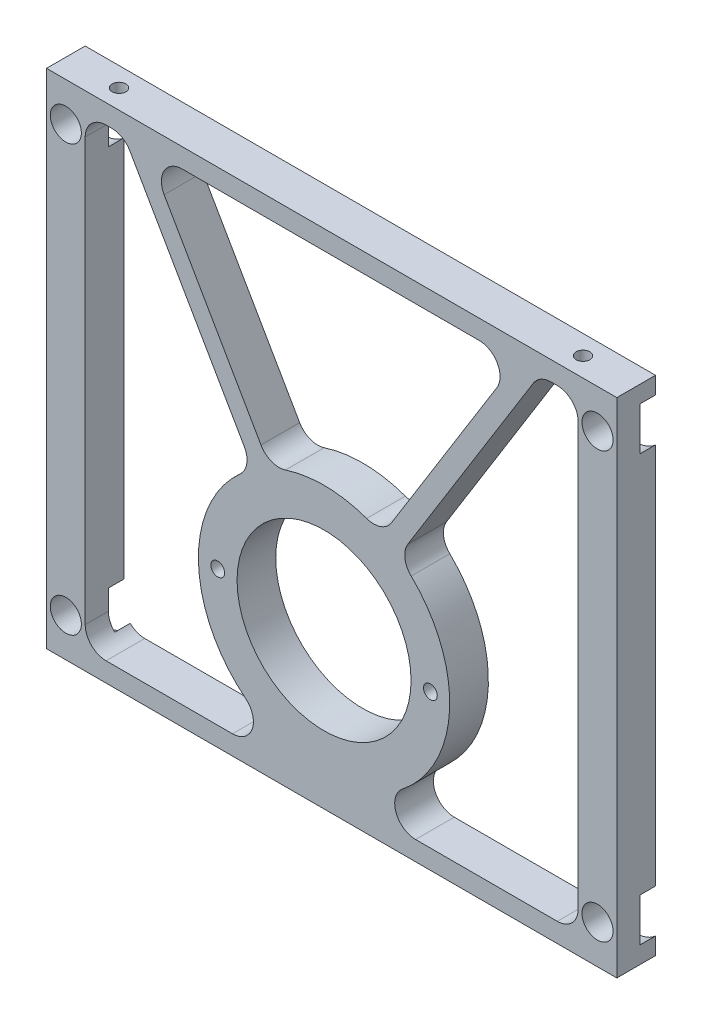
from build123d import *

# Parameters (mm, degrees)
SKETCH1_W                                           = 93.6625
SKETCH1_H                                           = 82.55
SKETCH1_R                                           = 14.2875
BOSS_EXTRUDE1_DEPTH                                 = 6.35
F_4_40_TAPPED_HOLE2_D                               = 2.2606
CUT_EXTRUDE1_DEPTH                                  = 7.35
FILLET1_R                                           = 3.429
CBORE_FOR_10_BINDING_HEAD_MACHINE_SCREW_D           = 5.1054
CBORE_FOR_10_BINDING_HEAD_MACHINE_SCREW_CBORE_D     = 9.525
CBORE_FOR_10_BINDING_HEAD_MACHINE_SCREW_CBORE_DEPTH = 2.54
F_4_40_TAPPED_HOLE1_D                               = 2.2606
F_4_40_TAPPED_HOLE1_DEPTH                           = 10.16
F_4_40_TAPPED_HOLE1_TIP                             = 0.679152758


with BuildPart() as part:
    # Sketch1 → Boss-Extrude1 (new body)
    with BuildSketch(Plane.XY):
        with Locations((10.31875, -15.875)):
            Rectangle(SKETCH1_W, SKETCH1_H)
        with Locations((9.069614104, -31.75)):
            Circle(SKETCH1_R, mode=Mode.SUBTRACT)
    extrude(amount=BOSS_EXTRUDE1_DEPTH)

    # #4-40 Tapped Hole2 (through all)
    with Locations(Plane.XY.offset(6.35)):
        with Locations((26.532114104, -31.75), (-8.392885896, -31.75)):
            Hole(F_4_40_TAPPED_HOLE2_D / 2)

    # Sketch2 → Cut-Extrude1 (cut, through all)
    with BuildSketch(Plane.XY.offset(6.35)):
        with BuildLine():
            Line((-20.149609941, 22.225), (40.712811593, 22.225))
            Line((40.712811593, 22.225), (18.574480492, -13.431596107))
            ThreePointArc((18.574480492, -13.431596107), (9.416149426, -11.115409635), (0.185209158, -13.122768456))
            Line((0.185209158, -13.122768456), (-20.149609941, 22.225))
        make_face()
        with BuildLine():
            Line((-2.566886821, -14.705990716), (-23.8125, 22.225))
            Line((-23.8125, 22.225), (-30.1625, 22.225))
            Line((-30.1625, 22.225), (-30.1625, -53.975))
            Line((-30.1625, -53.975), (-23.8125, -53.975))
            Line((-23.8125, -53.975), (-5.960582377, -53.975))
            ThreePointArc((-5.960582377, -53.975), (-2.724759294, -51.680676155), (-3.819076809, -47.867941953))
            ThreePointArc((-3.819076809, -47.867941953), (-6.448418302, -45.355038643), (-8.595789137, -42.419579868))
            ThreePointArc((-8.595789137, -42.419579868), (-11.096227135, -27.363058767), (-2.566886821, -14.705990716))
        make_face()
        with BuildLine():
            Line((50.8, -53.975), (44.45, -53.975))
            Line((44.45, -53.975), (24.099810585, -53.975))
            ThreePointArc((24.099810585, -53.975), (20.863987502, -51.680676155), (21.958305018, -47.867941953))
            ThreePointArc((21.958305018, -47.867941953), (24.826645515, -45.077504169), (27.102527574, -41.785957255))
            ThreePointArc((27.102527574, -41.785957255), (29.231255822, -27.343798747), (21.271862562, -15.106336376))
            Line((21.271862562, -15.106336376), (44.45, 22.225))
            Line((44.45, 22.225), (50.8, 22.225))
            Line((50.8, 22.225), (50.8, -53.975))
        make_face()
    extrude(amount=-CUT_EXTRUDE1_DEPTH, mode=Mode.SUBTRACT)

    # Fillet1
    fillet1_edges = [part.edges().sort_by_distance(p)[0] for p in [
        (0.185209158, -13.122768456, 3.175),
        (-20.149609941, 22.225, 3.175),
        (40.712811593, 22.225, 3.175),
        (18.574480492, -13.431596107, 3.175),
        (-30.1625, 22.225, 3.175),
        (-23.8125, 22.225, 3.175),
        (-2.566886821, -14.705990716, 3.175),
        (-30.1625, -53.975, 3.175),
        (50.8, 22.225, 3.175),
        (50.8, -53.975, 3.175),
        (21.271862562, -15.106336376, 3.175),
        (44.45, 22.225, 3.175),
    ]]
    fillet(fillet1_edges, radius=FILLET1_R)

    # CBORE for #10 Binding Head Machine Screw1 (through all)
    with Locations(Plane(origin=(0, 0, 0), x_dir=(-1, 0, 0), z_dir=(0, 0, -1))):
        with Locations((33.3375, 19.05), (-53.975, 19.05), (-53.975, -50.8), (33.3375, -50.8)):
            CounterBoreHole(CBORE_FOR_10_BINDING_HEAD_MACHINE_SCREW_D / 2, CBORE_FOR_10_BINDING_HEAD_MACHINE_SCREW_CBORE_D / 2, CBORE_FOR_10_BINDING_HEAD_MACHINE_SCREW_CBORE_DEPTH)

    # #4-40 Tapped Hole1
    with Locations(Plane(origin=(0, 25.4, 90.4875), x_dir=(1, 0, 0), z_dir=(0, 1, 0))):
        with Locations((48.41875, 87.3125), (-27.78125, 87.3125), (-27.78125, 3.175), (48.41875, 3.175)):
            Hole(F_4_40_TAPPED_HOLE1_D / 2, depth=F_4_40_TAPPED_HOLE1_DEPTH)
            with Locations((0, 0, -(F_4_40_TAPPED_HOLE1_DEPTH + F_4_40_TAPPED_HOLE1_TIP / 2))):  # 118° drill point
                Cone(0, F_4_40_TAPPED_HOLE1_D / 2, F_4_40_TAPPED_HOLE1_TIP, mode=Mode.SUBTRACT)


solid = part.part
